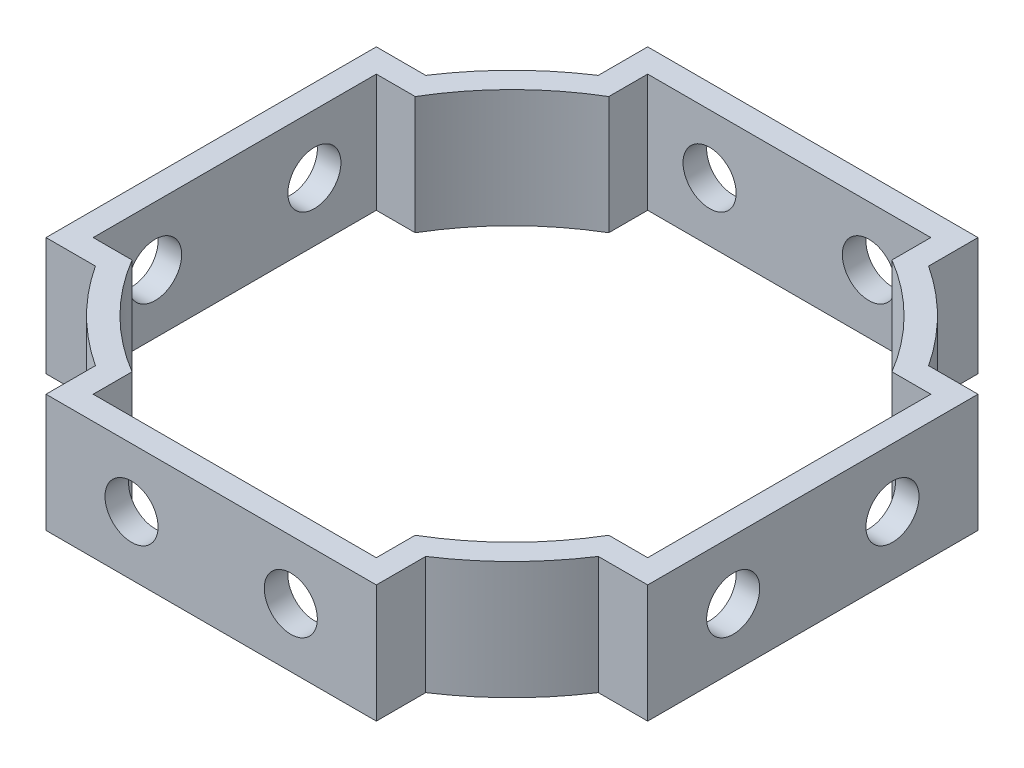
from build123d import *

# Parameters (mm, degrees)
SKETCH_1_R          = 25.5
SKETCH_1_R_2        = 23.5
EXTRUDE_1_DEPTH     = 10
EXTRUDE_2_DEPTH     = 10
SKETCH_3_R          = 2.25
CUT_EXTRUDE_1_DEPTH = 52
SKETCH_4_R          = 2.25
CUT_EXTRUDE_2_DEPTH = 52
SKETCH_7_W          = 24
SKETCH_7_H          = 3.731601122
SKETCH_7_W_2        = 3.731601122
SKETCH_7_H_2        = 24
CUT_EXTRUDE_4_DEPTH = 11.0000001


with BuildPart() as part:
    # 草图1 → 凸台-拉伸1 (new body)
    with BuildSketch(Plane(origin=(0, 0, 0), x_dir=(1, 0, 0), z_dir=(0, 1, 0))):
        Circle(SKETCH_1_R)
        Circle(SKETCH_1_R_2, mode=Mode.SUBTRACT)
    extrude(amount=EXTRUDE_1_DEPTH)

    # 草图2 → 凸台-拉伸2 (add)
    with BuildSketch(Plane(origin=(0, 10, 0), x_dir=(1, 0, 0), z_dir=(0, 1, 0))):
        with BuildLine():
            Line((-14, 25.5), (14, 25.5))
            Line((14, 25.5), (14, 20.205197351))
            ThreePointArc((14, 20.205197351), (0, 24.581497107), (-14, 20.205197351))
            Line((-14, 20.205197351), (-14, 25.5))
        make_face()
        with BuildLine():
            Line((20.205197351, 14), (25.5, 14))
            Line((25.5, 14), (25.5, -14))
            Line((25.5, -14), (20.205197351, -14))
            ThreePointArc((20.205197351, -14), (24.581497107, 0), (20.205197351, 14))
        make_face()
        with BuildLine():
            Line((14, -20.205197351), (14, -25.5))
            Line((14, -25.5), (-14, -25.5))
            Line((-14, -25.5), (-14, -20.205197351))
            ThreePointArc((-14, -20.205197351), (0, -24.581497107), (14, -20.205197351))
        make_face()
        with BuildLine():
            Line((-20.205197351, -14), (-25.5, -14))
            Line((-25.5, -14), (-25.5, 14))
            Line((-25.5, 14), (-20.205197351, 14))
            ThreePointArc((-20.205197351, 14), (-24.581497107, 0), (-20.205197351, -14))
        make_face()
    extrude(amount=-EXTRUDE_2_DEPTH)

    # 草图3 → 切除-拉伸1 (cut, through all)
    with BuildSketch(Plane.XY.offset(25.5)):
        with Locations((-6.75, 5)):
            Circle(SKETCH_3_R)
        with Locations((6.75, 5)):
            Circle(SKETCH_3_R)
    extrude(amount=-CUT_EXTRUDE_1_DEPTH, mode=Mode.SUBTRACT)

    # 草图4 → 切除-拉伸2 (cut, through all)
    with BuildSketch(Plane.ZY.offset(25.5)):
        with Locations((-6.75, 5)):
            Circle(SKETCH_4_R)
        with Locations((6.75, 5)):
            Circle(SKETCH_4_R)
    extrude(amount=-CUT_EXTRUDE_2_DEPTH, mode=Mode.SUBTRACT)

    # 草图7 → 切除-拉伸4 (cut, through all)
    with BuildSketch(Plane(origin=(0, 10, 0), x_dir=(1, 0, 0), z_dir=(0, 1, 0))):
        with Locations((0, 21.634199439)):
            Rectangle(SKETCH_7_W, SKETCH_7_H)
        with Locations((21.634199439, 0)):
            Rectangle(SKETCH_7_W_2, SKETCH_7_H_2)
        with Locations((0, -21.634199439)):
            Rectangle(SKETCH_7_W, SKETCH_7_H)
        with Locations((-21.634199439, 0)):
            Rectangle(SKETCH_7_W_2, SKETCH_7_H_2)
    extrude(amount=-CUT_EXTRUDE_4_DEPTH, mode=Mode.SUBTRACT)


solid = part.part
